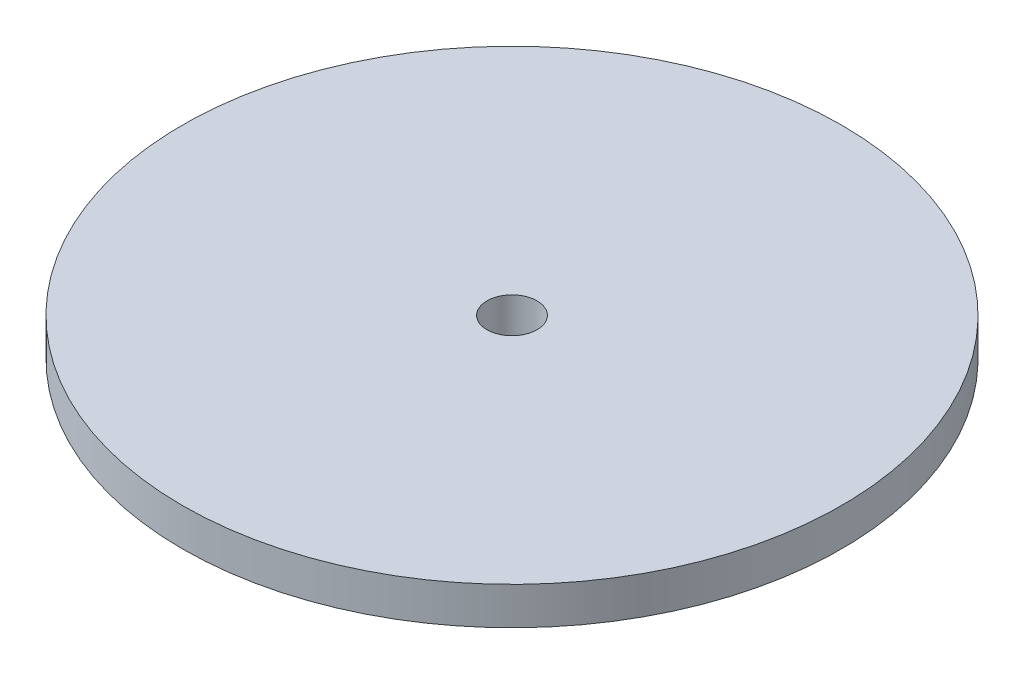
from build123d import *

# Parameters (mm, degrees)
SKETCH1_R           = 10.5
SKETCH1_R_2         = 1
BOSS_EXTRUDE1_DEPTH = 1.5
SKETCH2_R           = 13.15
SKETCH2_R_2         = 10.5
SKETCH2_R_3         = 1
BOSS_EXTRUDE2_DEPTH = 1.5
SKETCH4_R           = 10.5
CUT_EXTRUDE1_DEPTH  = 1.5


with BuildPart() as part:
    # Sketch1 → Boss-Extrude1 (new body)
    with BuildSketch(Plane(origin=(0, 0, 0), x_dir=(1, 0, 0), z_dir=(0, 1, 0))):
        with Locations(Location((0, 0, 0), (0, 0, 270))):
            Circle(SKETCH1_R)
        with Locations(Location((0, 0, 0), (0, 0, 270))):
            Circle(SKETCH1_R_2, mode=Mode.SUBTRACT)
    extrude(amount=BOSS_EXTRUDE1_DEPTH)

    # Sketch2 → Boss-Extrude2 (add)
    with BuildSketch(Plane(origin=(0, 1.5, 0), x_dir=(1, 0, 0), z_dir=(0, 1, 0))):
        with Locations(Location((0, 0, 0), (0, 0, 270))):
            Circle(SKETCH2_R)
        with Locations(Location((0, 0, 0), (0, 0, 270))):
            Circle(SKETCH2_R_2, mode=Mode.SUBTRACT)
        with Locations(Location((0, 0, 0), (0, 0, 270))):
            Circle(SKETCH2_R_2)
        with Locations(Location((0, 0, 0), (0, 0, 270))):
            Circle(SKETCH2_R_3, mode=Mode.SUBTRACT)
    extrude(amount=BOSS_EXTRUDE2_DEPTH)

    # Sketch4 → Cut-Extrude1 (cut)
    with BuildSketch(Plane.XZ):
        Circle(SKETCH4_R)
    extrude(amount=-CUT_EXTRUDE1_DEPTH, mode=Mode.SUBTRACT)


solid = part.part
